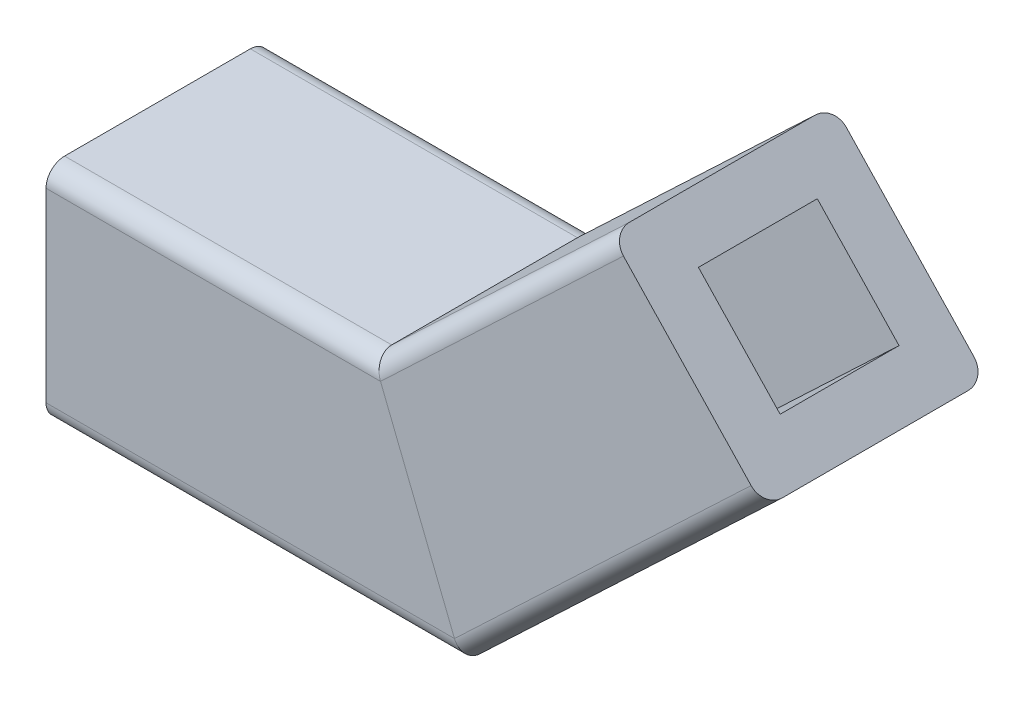
from build123d import *

# Parameters (mm, degrees)
SKETCH3_W   = 6
SKETCH3_H   = 6
SKETCH3_W_2 = 3.2
SKETCH3_H_2 = 3.2
FILLET1_R   = 0.5


with BuildPart() as part:
    # Sweep1: sweep along a path in Sketch2
    with BuildLine(Plane.XY) as sweep1_path:
        Line((0, 0), (10, 0))
        Line((10, 0), (17.262148132, 6.874678502))
    # Sketch3 → Sweep1 (sweep)
    with BuildSketch(Plane(origin=(0, 0, 0), x_dir=(0, 0, -1), z_dir=(1, 0, 0))):
        Rectangle(SKETCH3_W, SKETCH3_H)
        Rectangle(SKETCH3_W_2, SKETCH3_H_2, mode=Mode.SUBTRACT)
    sweep(path=sweep1_path.line, transition=Transition.RIGHT)

    # Fillet1
    fillet1_edges = [part.edges().sort_by_distance(p)[0] for p in [
        (5.597377434, -3, 3),
        (4.402622566, 3, 3),
        (4.402622566, 3, -3),
        (5.597377434, -3, -3),
        (15.259653275, 0.848017031, -3),
        (12.002494857, 6.026661471, -3),
        (12.002494857, 6.026661471, 3),
        (15.259653275, 0.848017031, 3),
    ]]
    fillet(fillet1_edges, radius=FILLET1_R)


solid = part.part
